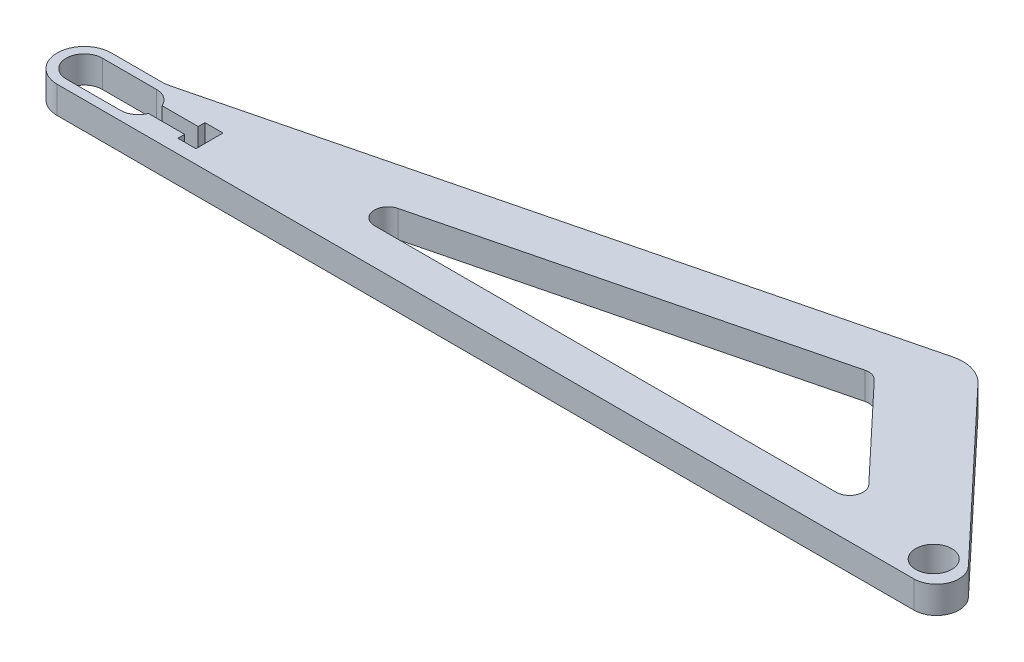
from build123d import *

# Parameters (mm, degrees)
SKETCH1_R           = 12.7
BOSS_EXTRUDE1_DEPTH = 19.05


with BuildPart() as part:
    # Sketch1 → Boss-Extrude1 (new body)
    with BuildSketch(Plane(origin=(0, 0, 0), x_dir=(1, 0, 0), z_dir=(0, 1, 0))):
        with BuildLine():
            Line((0, -19.05), (-558.8, -19.05))
            Line((-558.8, -19.05), (-596.9, -19.05))
            ThreePointArc((-596.9, -19.05), (-615.95, 0), (-596.9, 19.05))
            Line((-596.9, 19.05), (-561.926882891, 19.05))
            ThreePointArc((-561.926882891, 19.05), (-558.823427993, 19.24030806), (-555.766478015, 19.808380496))
            Line((-555.766478015, 19.808380496), (-116.049044826, 129.737738793))
            ThreePointArc((-116.049044826, 129.737738793), (-102.738548138, 129.468976879), (-91.392360136, 122.504382644))
            Line((-91.392360136, 122.504382644), (0, 25.4))
            Line((0, 25.4), (16.653962733, 7.705164597))
            ThreePointArc((16.653962733, 7.705164597), (19.666677712, -9.47154715), (5.093787849, -19.05))
            Line((5.093787849, -19.05), (0, -19.05))
        make_face()
        Circle(SKETCH1_R, mode=Mode.SUBTRACT)
        with BuildLine():
            Line((-596.9, -12.7), (-558.8, -12.7))
            ThreePointArc((-558.8, -12.7), (-551.700484171, -10.530283709), (-547.026784902, -4.7625))
            Line((-547.026784902, -4.7625), (-521.626784902, -4.7625))
            Line((-521.626784902, -4.7625), (-521.626784902, -9.525))
            Line((-521.626784902, -9.525), (-508.926784902, -9.525))
            Line((-508.926784902, -9.525), (-508.926784902, 9.525))
            Line((-508.926784902, 9.525), (-521.626784902, 9.525))
            Line((-521.626784902, 9.525), (-521.626784902, 4.7625))
            Line((-521.626784902, 4.7625), (-547.026784902, 4.7625))
            ThreePointArc((-547.026784902, 4.7625), (-551.700484171, 10.530283709), (-558.8, 12.7))
            Line((-558.8, 12.7), (-596.9, 12.7))
            ThreePointArc((-596.9, 12.7), (-609.6, 0), (-596.9, -12.7))
        make_face(mode=Mode.SUBTRACT)
        with BuildLine():
            Line((-401.666524357, 25.115607314), (-139.08105489, 90.761974681))
            ThreePointArc((-139.08105489, 90.761974681), (-134.089618632, 90.661188963), (-129.834798131, 88.049466125))
            Line((-129.834798131, 88.049466125), (-68.049981786, 22.403098758))
            ThreePointArc((-68.049981786, 22.403098758), (-66.242352798, 12.09707171), (-74.986086716, 6.35))
            Line((-74.986086716, 6.35), (-399.356372528, 6.35))
            ThreePointArc((-399.356372528, 6.35), (-408.810007006, 14.711204413), (-401.666524357, 25.115607314))
        make_face(mode=Mode.SUBTRACT)
    extrude(amount=BOSS_EXTRUDE1_DEPTH)


solid = part.part
